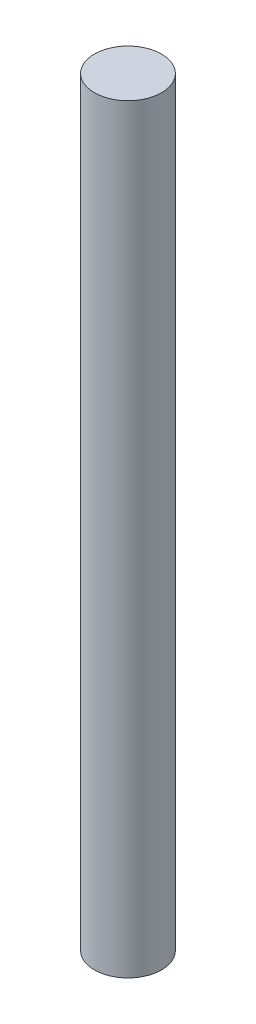
from build123d import *

# Parameters (mm, degrees)
PROFILE_SKETCH_R    = 4
BOSS_EXTRUDE1_DEPTH = 90.6018


with BuildPart() as part:
    # Profile Sketch → Boss-Extrude1 (new body)
    with BuildSketch(Plane(origin=(0, 0, 0), x_dir=(1, 0, 0), z_dir=(0, 1, 0))):
        Circle(PROFILE_SKETCH_R)
    extrude(amount=BOSS_EXTRUDE1_DEPTH)


solid = part.part
